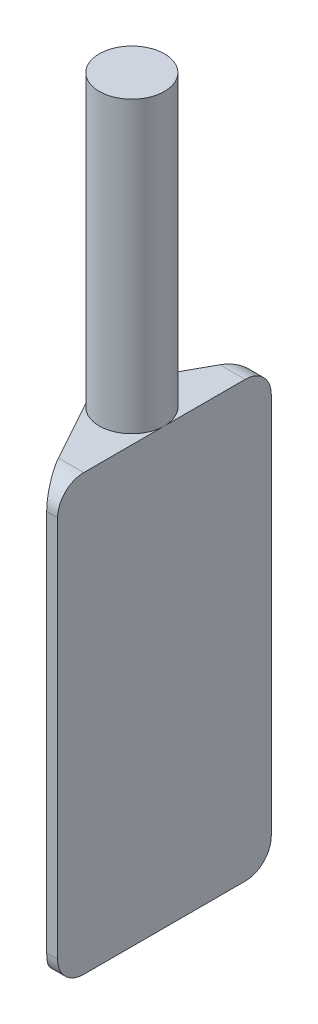
from build123d import *

# Parameters (mm, degrees)
CROQUIS1_R              = 9
SALIENTE_EXTRUIR1_DEPTH = 200
SALIENTE_EXTRUIR2_DEPTH = 120
REDONDEO1_R             = 7.2
CORTAR_EXTRUIR1_DEPTH   = 120


with BuildPart() as part:
    # Croquis1 → Saliente-Extruir1 (new body)
    with BuildSketch(Plane(origin=(0, 0, 0), x_dir=(1, 0, 0), z_dir=(0, 1, 0))):
        Circle(CROQUIS1_R)
    extrude(amount=SALIENTE_EXTRUIR1_DEPTH)

    # Croquis2 → Saliente-Extruir2 (add)
    with BuildSketch(Plane.XZ):
        with BuildLine():
            Line((6, 29.5), (-7.879793, 4.348432))
            ThreePointArc((-7.879793, 4.348432), (-9, 0), (-7.879793, -4.348432))
            Line((-7.879793, -4.348432), (6, -29.5))
            Line((6, -29.5), (9, -29.5))
            Line((9, -29.5), (9, 29.5))
            Line((9, 29.5), (6, 29.5))
        make_face()
    extrude(amount=-SALIENTE_EXTRUIR2_DEPTH)

    # Redondeo1
    redondeo1_edges = [part.edges().sort_by_distance(p)[0] for p in [
        (7.5, 0, 29.5),
        (7.5, 120, 29.5),
        (7.5, 120, -29.5),
        (7.5, 0, -29.5),
    ]]
    fillet(redondeo1_edges, radius=REDONDEO1_R)

    # Croquis3 → Cortar-Extruir1 (cut)
    with BuildSketch(Plane(origin=(0, 0, -29.5), x_dir=(-1, 0, 0), z_dir=(0, 0, -1))):
        Polygon((-2.026709, 0), (10.656807, 15.115625), (12.907476, -4.543474), align=None)
    extrude(amount=-CORTAR_EXTRUIR1_DEPTH, mode=Mode.SUBTRACT)


solid = part.part
